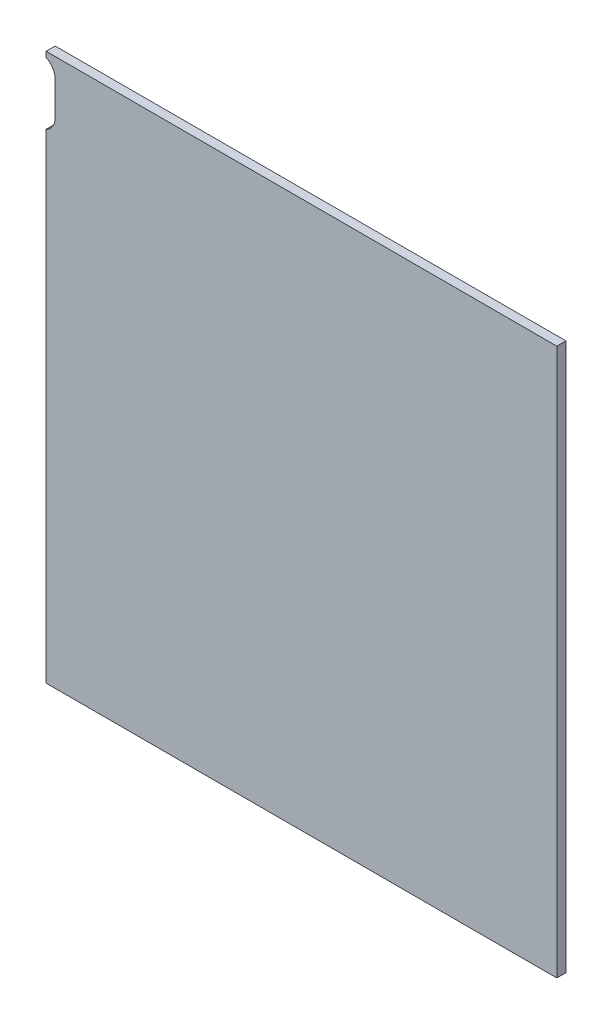
from build123d import *

# Parameters (mm, degrees)
SKETCH1_W           = 280
SKETCH1_H           = 300
BOSS_EXTRUDE1_DEPTH = 5
CUT_EXTRUDE1_DEPTH  = 6
BOSS_EXTRUDE2_DEPTH = 7
BOSS_EXTRUDE3_DEPTH = 5


with BuildPart() as part:
    # Sketch1 → Boss-Extrude1 (new body)
    with BuildSketch(Plane.XY):
        Rectangle(SKETCH1_W, SKETCH1_H)
    extrude(amount=BOSS_EXTRUDE1_DEPTH)

    # Sketch2 → Cut-Extrude1 (cut, through all)
    with BuildSketch(Plane.XY.offset(5)):
        with BuildLine():
            Line((-153, 139), (-153, 121))
            ThreePointArc((-153, 121), (-144, 112), (-135, 121))
            Line((-135, 121), (-135, 139))
            ThreePointArc((-135, 139), (-144, 148), (-153, 139))
        make_face()
    extrude(amount=-CUT_EXTRUDE1_DEPTH, mode=Mode.SUBTRACT)

    # Sketch3 → Boss-Extrude2 (add)
    with BuildSketch(Plane(origin=(0, 0, 0), x_dir=(-1, 0, 0), z_dir=(0, 0, -1))):
        Polygon((-82.857142857, -101.5), (-14.483171201, -116.5), (-16.626028344, -126.267710237), (-85, -111.267710237), align=None)
    extrude(amount=BOSS_EXTRUDE2_DEPTH)

    # Sketch4 → Boss-Extrude3 (add)
    with BuildSketch(Plane(origin=(0, 0, -7), x_dir=(-1, 0, 0), z_dir=(0, 0, -1))):
        Polygon((-82.857142857, -101.5), (-14.483171201, -116.5), (-17.697456916, -131.151565355), (-86.071428571, -116.151565355), align=None)
    extrude(amount=BOSS_EXTRUDE3_DEPTH)


solid = part.part
